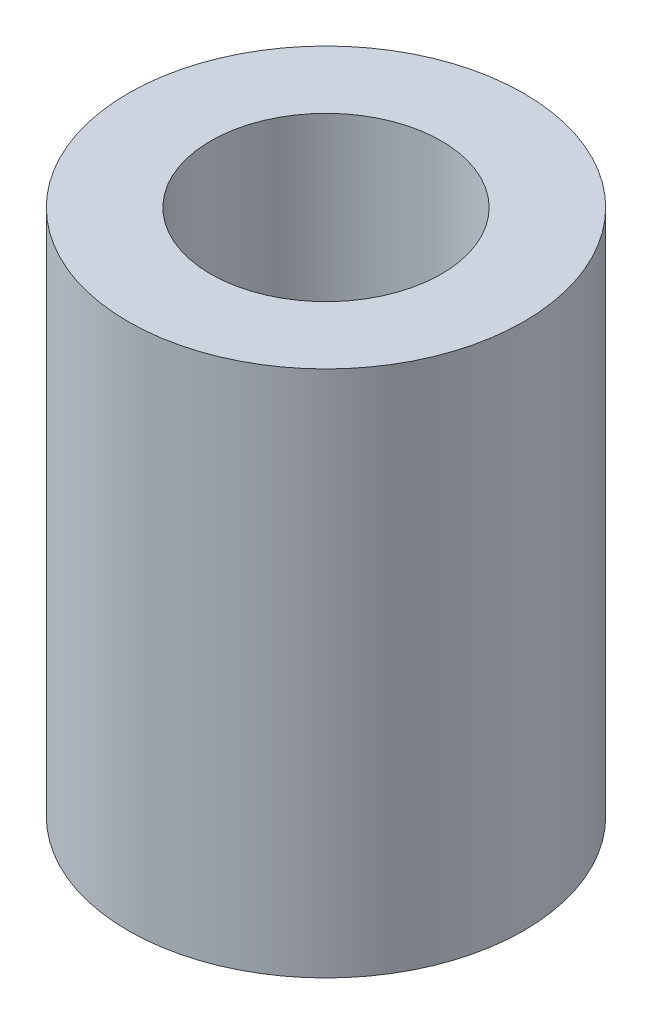
from build123d import *

# Parameters (mm, degrees)
SKETCH1_R           = 3
SKETCH1_R_2         = 1.75
BOSS_EXTRUDE1_DEPTH = 4


with BuildPart() as part:
    # Sketch1 → Boss-Extrude1 (new body, symmetric)
    with BuildSketch(Plane(origin=(0, 0, 0), x_dir=(1, 0, 0), z_dir=(0, 1, 0))):
        Circle(SKETCH1_R)
        Circle(SKETCH1_R_2, mode=Mode.SUBTRACT)
    extrude(amount=BOSS_EXTRUDE1_DEPTH, both=True)


solid = part.part
